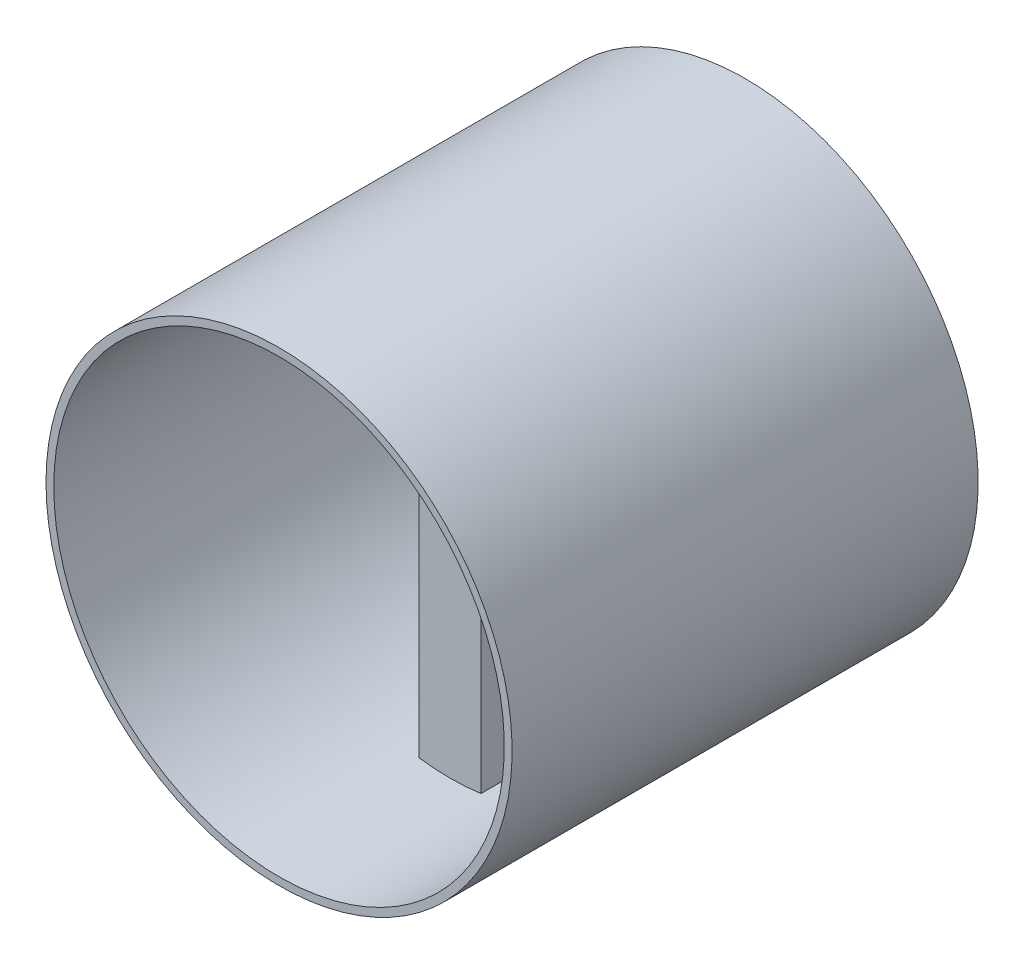
from build123d import *

# Parameters (mm, degrees)
ESQUISSE1_W             = 8
ESQUISSE1_H             = 59
BOSS_EXTRU_1_DEPTH      = 60
ESQUISSE3_R             = 30
ESQUISSE3_R_2           = 29
BOSS_EXTRU_2_DEPTH      = 60
ESQUISSE4_R             = 29
ENL_V_MAT_EXTRU_3_DEPTH = 30
ENL_V_MAT_EXTRU_5_DEPTH = 1.5
ESQUISSE6_R             = 29
ENL_V_MAT_EXTRU_6_DEPTH = 22
ESQUISSE7_R             = 2
ENL_V_MAT_EXTRU_7_DEPTH = 6.5
ESQUISSE9_R             = 2
BOSS_EXTRU_4_DEPTH      = 6.5
ESQUISSE10_R            = 2
ENL_V_MAT_EXTRU_8_DEPTH = 3.7
ESQUISSE11_R            = 0.75
ENL_V_MAT_EXTRU_9_DEPTH = 3.7


with BuildPart() as part:
    # Esquisse1 → Boss.-Extru.1 (new body)
    with BuildSketch(Plane.XY):
        with Locations((4, 29.5)):
            Rectangle(ESQUISSE1_W, ESQUISSE1_H)
    extrude(amount=BOSS_EXTRU_1_DEPTH)

    # Esquisse3 → Boss.-Extru.2 (add)
    with BuildSketch(Plane(origin=(0, 0, 0), x_dir=(-1, 0, 0), z_dir=(0, 0, -1))):
        with Locations((-4, 29.5)):
            Circle(ESQUISSE3_R)
        with Locations((-4, 29.5)):
            Circle(ESQUISSE3_R_2, mode=Mode.SUBTRACT)
    extrude(amount=-BOSS_EXTRU_2_DEPTH)

    # Esquisse4 → Enlèv. mat.-Extru.3 (cut)
    with BuildSketch(Plane(origin=(0, 0, 0), x_dir=(-1, 0, 0), z_dir=(0, 0, -1))):
        with Locations((-4, 29.5)):
            Circle(ESQUISSE4_R)
    extrude(amount=-ENL_V_MAT_EXTRU_3_DEPTH, mode=Mode.SUBTRACT)

    # Esquisse5 → Enlèv. mat.-Extru.5 (cut)
    with BuildSketch(Plane(origin=(0, 0, 30), x_dir=(-1, 0, 0), z_dir=(0, 0, -1))):
        with BuildLine():
            Line((-6, 43), (-6.967257844, 29.9420191))
            ThreePointArc((-6.967257844, 29.9420191), (-7, 29.5), (-6.967257844, 29.0579809))
            Line((-6.967257844, 29.0579809), (-6, 16))
            ThreePointArc((-6, 16), (-4, 14), (-2, 16))
            Line((-2, 16), (-1.032742156, 29.0579809))
            ThreePointArc((-1.032742156, 29.0579809), (-1, 29.5), (-1.032742156, 29.9420191))
            Line((-1.032742156, 29.9420191), (-2, 43))
            ThreePointArc((-2, 43), (-4, 45), (-6, 43))
        make_face()
    extrude(amount=-ENL_V_MAT_EXTRU_5_DEPTH, mode=Mode.SUBTRACT)

    # Esquisse6 → Enlèv. mat.-Extru.6 (cut)
    with BuildSketch(Plane.XY.offset(60)):
        with Locations((4, 29.5)):
            Circle(ESQUISSE6_R)
    extrude(amount=-ENL_V_MAT_EXTRU_6_DEPTH, mode=Mode.SUBTRACT)

    # Esquisse7 → Enlèv. mat.-Extru.7 (cut)
    with BuildSketch(Plane(origin=(0, 0, 31.5), x_dir=(-1, 0, 0), z_dir=(0, 0, -1))):
        with Locations((-4, 29.5)):
            Circle(ESQUISSE7_R)
    extrude(amount=-ENL_V_MAT_EXTRU_7_DEPTH, mode=Mode.SUBTRACT)

    # Esquisse9 → Boss.-Extru.4 (add)
    with BuildSketch(Plane.XY.offset(38)):
        with Locations((4, 29.5)):
            Circle(ESQUISSE9_R)
    extrude(amount=-BOSS_EXTRU_4_DEPTH)

    # Esquisse10 → Enlèv. mat.-Extru.8 (cut)
    with BuildSketch(Plane.XY.offset(38)):
        with Locations((4, 29.5)):
            Circle(ESQUISSE10_R)
    extrude(amount=-ENL_V_MAT_EXTRU_8_DEPTH, mode=Mode.SUBTRACT)

    # Esquisse11 → Enlèv. mat.-Extru.9 (cut)
    with BuildSketch(Plane.XY.offset(34.3)):
        with Locations((4, 29.5)):
            Circle(ESQUISSE11_R)
    extrude(amount=-ENL_V_MAT_EXTRU_9_DEPTH, mode=Mode.SUBTRACT)


solid = part.part
